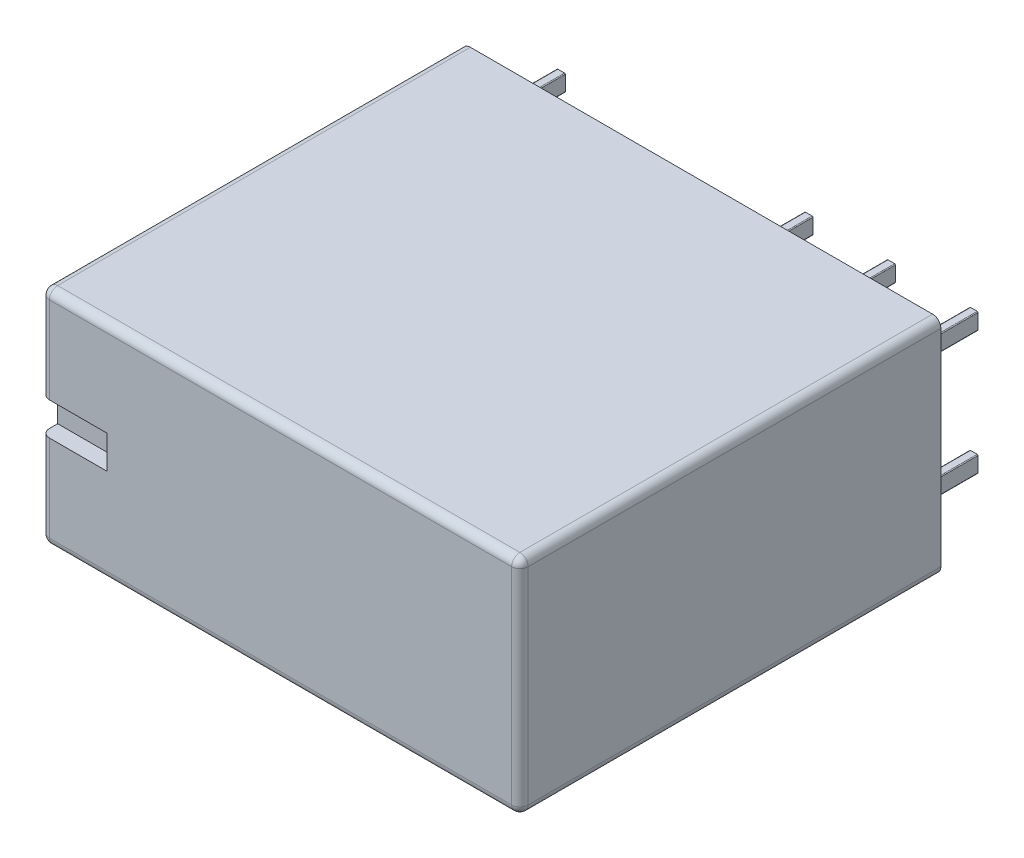
from build123d import *

# Parameters (mm, degrees)
SKETCH_1_W          = 29
SKETCH_1_H          = 13.5
EXTRUDE_1_DEPTH     = 25.5
FILLET_1_R          = 0.5
SKETCH_2_W          = 4
SKETCH_2_H          = 2
CUT_EXTRUDE_1_DEPTH = 1
SKETCH_3_W          = 0.5
SKETCH_3_H          = 1
EXTRUDE_2_DEPTH     = 4
FILLET_2_R          = 0.05


with BuildPart() as part:
    # Эскиз1 → Бобышка-Вытянуть1 (new body)
    with BuildSketch(Plane.XY):
        Rectangle(SKETCH_1_W, SKETCH_1_H)
    extrude(amount=EXTRUDE_1_DEPTH)

    # Скругление1
    fillet_1_edges = [part.edges().sort_by_distance(p)[0] for p in [
        (-14.5, 0, 25.5),
        (0, -6.75, 25.5),
        (14.5, 0, 25.5),
        (0, 6.75, 25.5),
        (14.5, -6.75, 12.75),
        (-14.5, -6.75, 12.75),
        (-14.5, 6.75, 12.75),
        (14.5, 6.75, 12.75),
    ]]
    fillet(fillet_1_edges, radius=FILLET_1_R)

    # Эскиз2 → Вырез-Вытянуть1 (cut)
    with BuildSketch(Plane.XY.offset(25.5)):
        with Locations((-12.5, 0.002144421)):
            Rectangle(SKETCH_2_W, SKETCH_2_H)
    extrude(amount=-CUT_EXTRUDE_1_DEPTH, mode=Mode.SUBTRACT)

    # Эскиз3 → Бобышка-Вытянуть2 (add)
    with BuildSketch(Plane(origin=(0, 0, 0), x_dir=(-1, 0, 0), z_dir=(0, 0, -1))):
        with Locations((12.5, -3.75)):
            Rectangle(SKETCH_3_W, SKETCH_3_H)
        with Locations((-2.5, -3.75)):
            Rectangle(SKETCH_3_W, SKETCH_3_H)
        with Locations((-7.5, -3.75)):
            Rectangle(SKETCH_3_W, SKETCH_3_H)
        with Locations((-12.5, -3.75)):
            Rectangle(SKETCH_3_W, SKETCH_3_H)
        with Locations((-12.5, 3.75)):
            Rectangle(SKETCH_3_W, SKETCH_3_H)
        with Locations((-7.5, 3.75)):
            Rectangle(SKETCH_3_W, SKETCH_3_H)
        with Locations((-2.5, 3.75)):
            Rectangle(SKETCH_3_W, SKETCH_3_H)
        with Locations((12.5, 3.75)):
            Rectangle(SKETCH_3_W, SKETCH_3_H)
    extrude(amount=EXTRUDE_2_DEPTH)

    # Скругление2
    fillet_2_edges = [part.edges().sort_by_distance(p)[0] for p in [
        (12.25, 3.25, -2),
        (12.25, 4.25, -2),
        (12.75, 4.25, -2),
        (12.75, 3.25, -2),
        (7.25, 3.25, -2),
        (7.25, 4.25, -2),
        (7.75, 4.25, -2),
        (7.75, 3.25, -2),
        (2.25, 3.25, -2),
        (2.25, 4.25, -2),
        (2.75, 4.25, -2),
        (2.75, 3.25, -2),
        (-12.75, 3.25, -2),
        (-12.75, 4.25, -2),
        (-12.25, 4.25, -2),
        (-12.25, 3.25, -2),
        (-12.25, -3.25, -2),
        (-12.25, -4.25, -2),
        (-12.75, -4.25, -2),
        (-12.75, -3.25, -2),
        (2.75, -3.25, -2),
        (2.75, -4.25, -2),
        (2.25, -4.25, -2),
        (2.25, -3.25, -2),
        (7.75, -3.25, -2),
        (7.75, -4.25, -2),
        (7.25, -4.25, -2),
        (7.25, -3.25, -2),
        (12.75, -3.25, -2),
        (12.75, -4.25, -2),
        (12.25, -4.25, -2),
        (12.25, -3.25, -2),
    ]]
    fillet(fillet_2_edges, radius=FILLET_2_R)


solid = part.part
